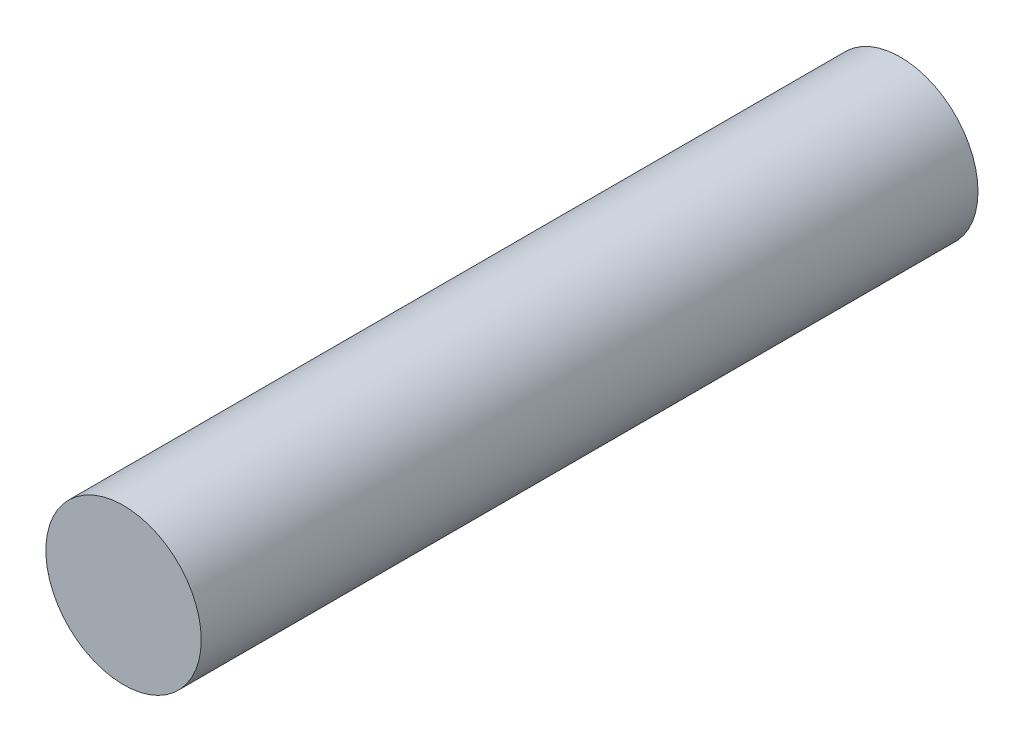
from build123d import *

# Parameters (mm, degrees)
SKETCH2_R           = 1.5
BOSS_EXTRUDE1_DEPTH = 15


with BuildPart() as part:
    # Sketch2 → Boss-Extrude1 (new body)
    with BuildSketch(Plane.XY):
        Circle(SKETCH2_R)
    extrude(amount=BOSS_EXTRUDE1_DEPTH)


solid = part.part
